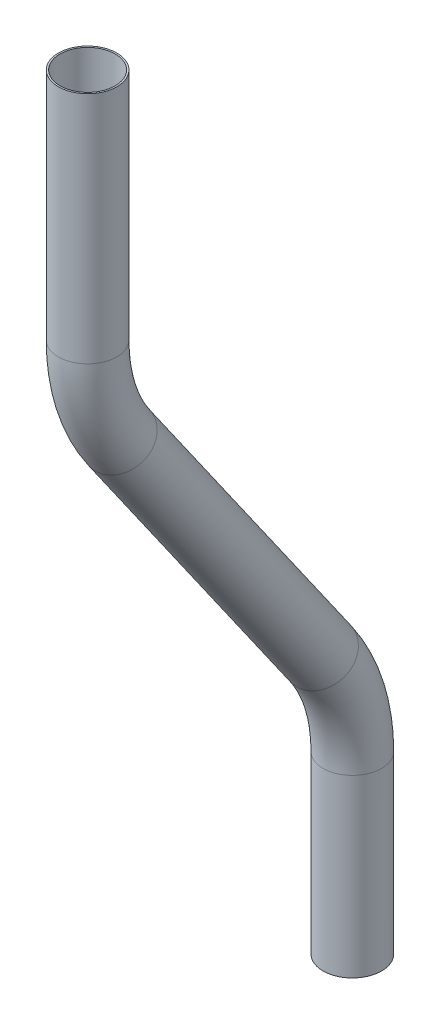
from build123d import *

# Parameters (mm, degrees)
SKETCH1_R   = 6.35
SKETCH1_R_2 = 5.995762211


with BuildPart() as part:
    # Sweep1: sweep along a path in Sketch2
    with BuildLine(Plane(origin=(0, 0, 0), x_dir=(0, 0, -1), z_dir=(1, 0, 0))) as sweep1_path:
        Line((0, 0), (0, 38.1))
        ThreePointArc((0, 38.1), (-1.763384176, 49.556890961), (-6.890307113, 59.953262225))
        Line((-6.890307113, 59.953262225), (-50.596831563, 122.372648))
        ThreePointArc((-50.596831563, 122.372648), (-55.723754499, 132.769019264), (-57.487138675, 144.225910225))
        Line((-57.487138675, 144.225910225), (-57.487138675, 195.025910225))
    # Sketch1 → Sweep1 (sweep)
    with BuildSketch(Plane(origin=(0, 0, 0), x_dir=(1, 0, 0), z_dir=(0, 1, 0))):
        Circle(SKETCH1_R)
        Circle(SKETCH1_R_2, mode=Mode.SUBTRACT)
    sweep(path=sweep1_path.line)


solid = part.part
